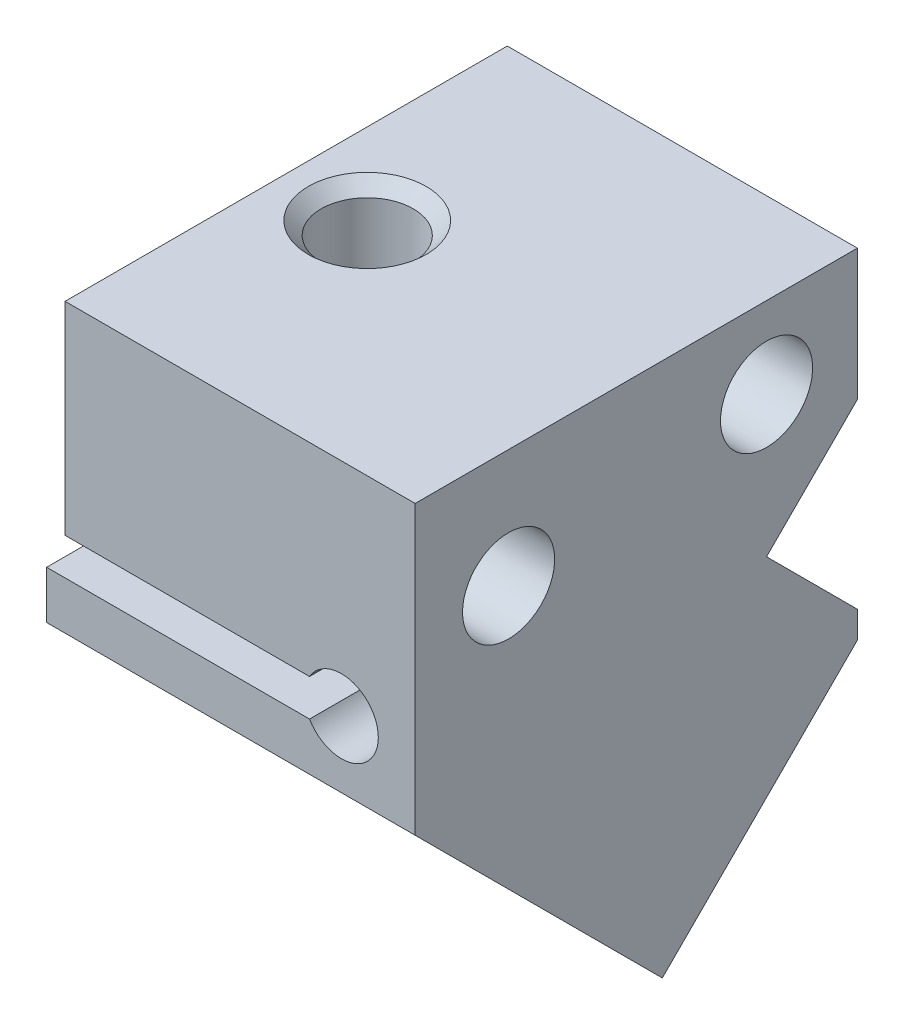
from build123d import *

# Parameters (mm, degrees)
EXTRUDE_1_DEPTH             = 10
SKETCH_2_W                  = 8
SKETCH_2_H                  = 15.737964923
CUT_EXTRUDE_1_DEPTH         = 2
CUT_EXTRUDE_2_DEPTH         = 13
HOLE_WIZARD_M31_D           = 2.5
HOLE_WIZARD_M31_CSINK_D     = 3.3
HOLE_WIZARD_M31_CSINK_ANGLE = 90
HOLE_WIZARD_M32_D           = 2.5
HOLE_WIZARD_M32_DEPTH       = 5.5
HOLE_WIZARD_M32_CSINK_D     = 3.2
HOLE_WIZARD_M32_CSINK_ANGLE = 90
CUT_EXTRUDE_START           = -8
SKETCH_9_W                  = 15.368263211
SKETCH_9_H                  = 5.398005259
CUT_EXTRUDE_3_DEPTH         = 4


with BuildPart() as part:
    # Эскиз1 → Бобышка-Вытянуть1 (new body)
    with BuildSketch(Plane(origin=(0, 0, 0), x_dir=(0, 0, -1), z_dir=(1, 0, 0))):
        Polygon((0, 0), (12, 0), (12, -9.213203436), (6.707106781, -14.506096654), (0, -7.798989873), align=None)
    extrude(amount=EXTRUDE_1_DEPTH)

    # Эскиз2 → Вырез-Вытянуть1 (cut)
    with BuildSketch(Plane(origin=(0, -10.606601718, -10.606601718), x_dir=(-1, 0, 0), z_dir=(0, -0.707106781, -0.707106781))):
        with Locations((-5, -0.262497876)):
            Rectangle(SKETCH_2_W, SKETCH_2_H)
    extrude(amount=-CUT_EXTRUDE_1_DEPTH, mode=Mode.SUBTRACT)

    # Эскиз3 → Вырез-Вытянуть2 (cut, through all)
    with BuildSketch(Plane.XY):
        with BuildLine():
            Line((0.5, -5.5), (0.5, 0))
            Line((0.5, 0), (0, 0))
            Line((0, 0), (0, -6.5))
            Line((0, -6.5), (7.133974596, -6.5))
            ThreePointArc((7.133974596, -6.5), (9, -6), (7.133974596, -5.5))
            Line((7.133974596, -5.5), (0.5, -5.5))
        make_face()
    extrude(amount=-CUT_EXTRUDE_2_DEPTH, mode=Mode.SUBTRACT)

    # Отверстие обработанное метчиком M31 (through all)
    with Locations(Plane.ZY):
        with Locations((-9.535533906, -2.202438662), (-2.535533906, -3.202438662)):
            CounterSinkHole(HOLE_WIZARD_M31_D / 2, HOLE_WIZARD_M31_CSINK_D / 2, counter_sink_angle=HOLE_WIZARD_M31_CSINK_ANGLE)

    # Отверстие обработанное метчиком M32
    with Locations(Plane(origin=(0, 0, 0), x_dir=(-1, 0, 0), z_dir=(0, 1, 0))):
        with Locations((-2.7, -6)):
            CounterSinkHole(HOLE_WIZARD_M32_D / 2, HOLE_WIZARD_M32_CSINK_D / 2, depth=HOLE_WIZARD_M32_DEPTH, counter_sink_angle=HOLE_WIZARD_M32_CSINK_ANGLE)

    # Эскиз9 → Вырез-Вытянуть3 (cut)
    with BuildSketch(Plane(origin=(0, -3.899494937, 3.899494937), x_dir=(1, 0, 0), z_dir=(0, -0.707106781, 0.707106781)).offset(CUT_EXTRUDE_START)):
        with Locations((3.917078905, -13.69900263)):
            Rectangle(SKETCH_9_W, SKETCH_9_H)
    extrude(amount=-CUT_EXTRUDE_3_DEPTH, mode=Mode.SUBTRACT)


solid = part.part
